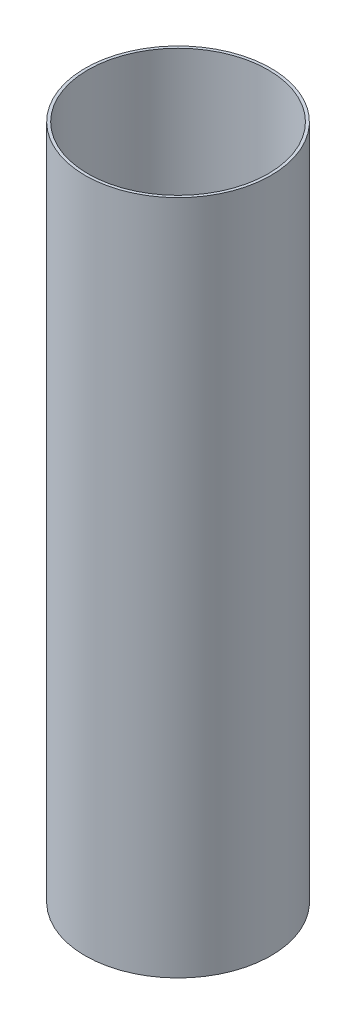
from build123d import *

# Parameters (mm, degrees)
SKETCH1_R           = 104.775
SKETCH1_R_2         = 101.6
BOSS_EXTRUDE1_DEPTH = 762


with BuildPart() as part:
    # Sketch1 → Boss-Extrude1 (new body)
    with BuildSketch(Plane(origin=(0, 0, 0), x_dir=(1, 0, 0), z_dir=(0, 1, 0))):
        Circle(SKETCH1_R)
        Circle(SKETCH1_R_2, mode=Mode.SUBTRACT)
    extrude(amount=BOSS_EXTRUDE1_DEPTH)


solid = part.part
